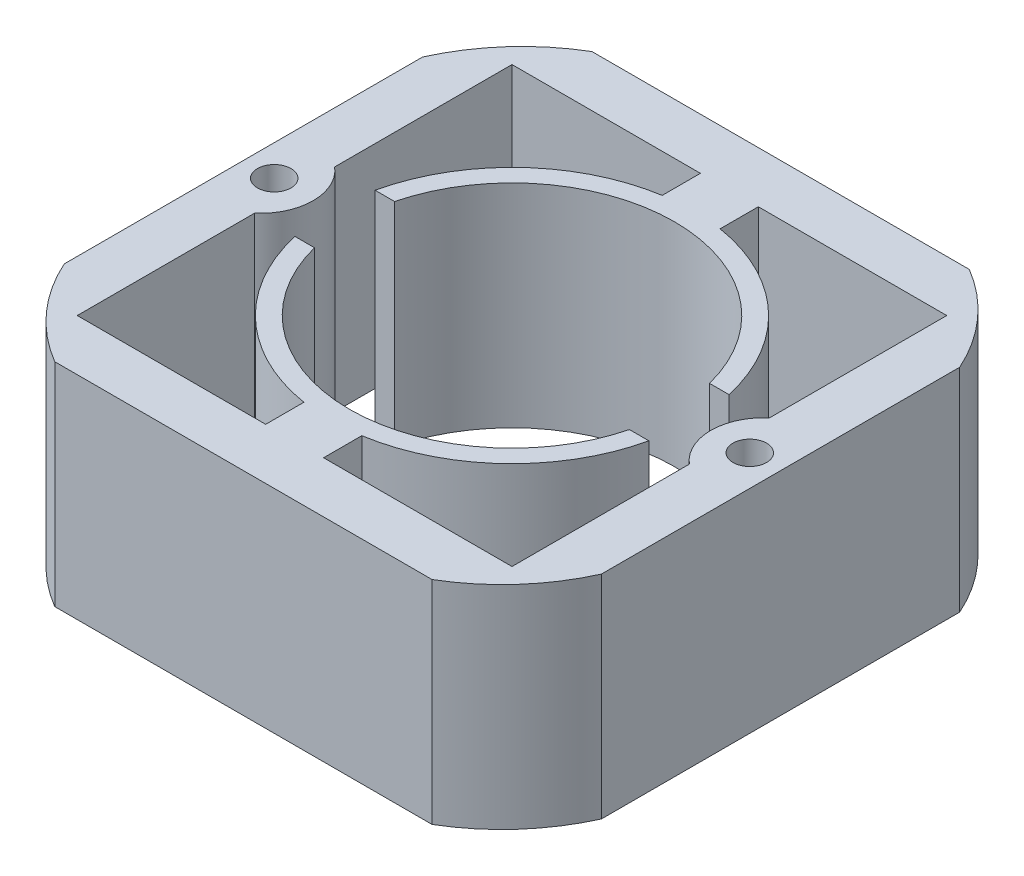
from build123d import *

# Parameters (mm, degrees)
SKETCH1_R           = 2.01295
BOSS_EXTRUDE1_DEPTH = 25.4


with BuildPart() as part:
    # Sketch1 → Boss-Extrude1 (new body)
    with BuildSketch(Plane(origin=(0, 0, 0), x_dir=(1, 0, 0), z_dir=(0, 1, 0))):
        with BuildLine():
            ThreePointArc((32.16275, -21.451406337), (28.205815008, -27.54883493), (22.589075945, -32.16275))
            Line((22.589075945, -32.16275), (-22.589075945, -32.16275))
            ThreePointArc((-22.589075945, -32.16275), (-28.205815008, -27.54883493), (-32.16275, -21.451406337))
            Line((-32.16275, -21.451406337), (-32.16275, 21.451406337))
            ThreePointArc((-32.16275, 21.451406337), (-28.205815008, 27.54883493), (-22.589075945, 32.16275))
            Line((-22.589075945, 32.16275), (22.589075945, 32.16275))
            ThreePointArc((22.589075945, 32.16275), (28.205815008, 27.54883493), (32.16275, 21.451406337))
            Line((32.16275, 21.451406337), (32.16275, -21.451406337))
        make_face()
        with Locations((-28.4734, 0)):
            Circle(SKETCH1_R, mode=Mode.SUBTRACT)
        with Locations((28.4734, 0)):
            Circle(SKETCH1_R, mode=Mode.SUBTRACT)
        with BuildLine():
            Line((3.466558561, -21.451406337), (3.466558561, -26.02865))
            Line((3.466558561, -26.02865), (26.02865, -26.02865))
            Line((26.02865, -26.02865), (26.02865, -4.794756681))
            ThreePointArc((26.02865, -4.794756681), (23.812095234, 0), (26.02865, 4.794756681))
            Line((26.02865, 4.794756681), (26.02865, 26.02865))
            Line((26.02865, 26.02865), (3.466558561, 26.02865))
            Line((3.466558561, 26.02865), (3.466558561, 21.451406337))
            ThreePointArc((3.466558561, 21.451406337), (14.879452296, 15.836090473), (21.194106975, 4.794756681))
            Line((21.194106975, 4.794756681), (18.856346659, 4.794756681))
            ThreePointArc((18.856346659, 4.794756681), (0, 19.4564), (-18.856346659, 4.794756681))
            Line((-18.856346659, 4.794756681), (-21.194106975, 4.794756681))
            ThreePointArc((-21.194106975, 4.794756681), (-14.879452296, 15.836090473), (-3.466558561, 21.451406337))
            Line((-3.466558561, 21.451406337), (-3.466558561, 26.02865))
            Line((-3.466558561, 26.02865), (-26.02865, 26.02865))
            Line((-26.02865, 26.02865), (-26.02865, 4.794756681))
            ThreePointArc((-26.02865, 4.794756681), (-23.812095234, 0), (-26.02865, -4.794756681))
            Line((-26.02865, -4.794756681), (-26.02865, -26.02865))
            Line((-26.02865, -26.02865), (-3.466558561, -26.02865))
            Line((-3.466558561, -26.02865), (-3.466558561, -21.451406337))
            ThreePointArc((-3.466558561, -21.451406337), (-14.879452296, -15.836090473), (-21.194106975, -4.794756681))
            Line((-21.194106975, -4.794756681), (-18.856346659, -4.794756681))
            ThreePointArc((-18.856346659, -4.794756681), (0, -19.4564), (18.856346659, -4.794756681))
            Line((18.856346659, -4.794756681), (21.194106975, -4.794756681))
            ThreePointArc((21.194106975, -4.794756681), (14.879452296, -15.836090473), (3.466558561, -21.451406337))
        make_face(mode=Mode.SUBTRACT)
    extrude(amount=BOSS_EXTRUDE1_DEPTH)


solid = part.part
